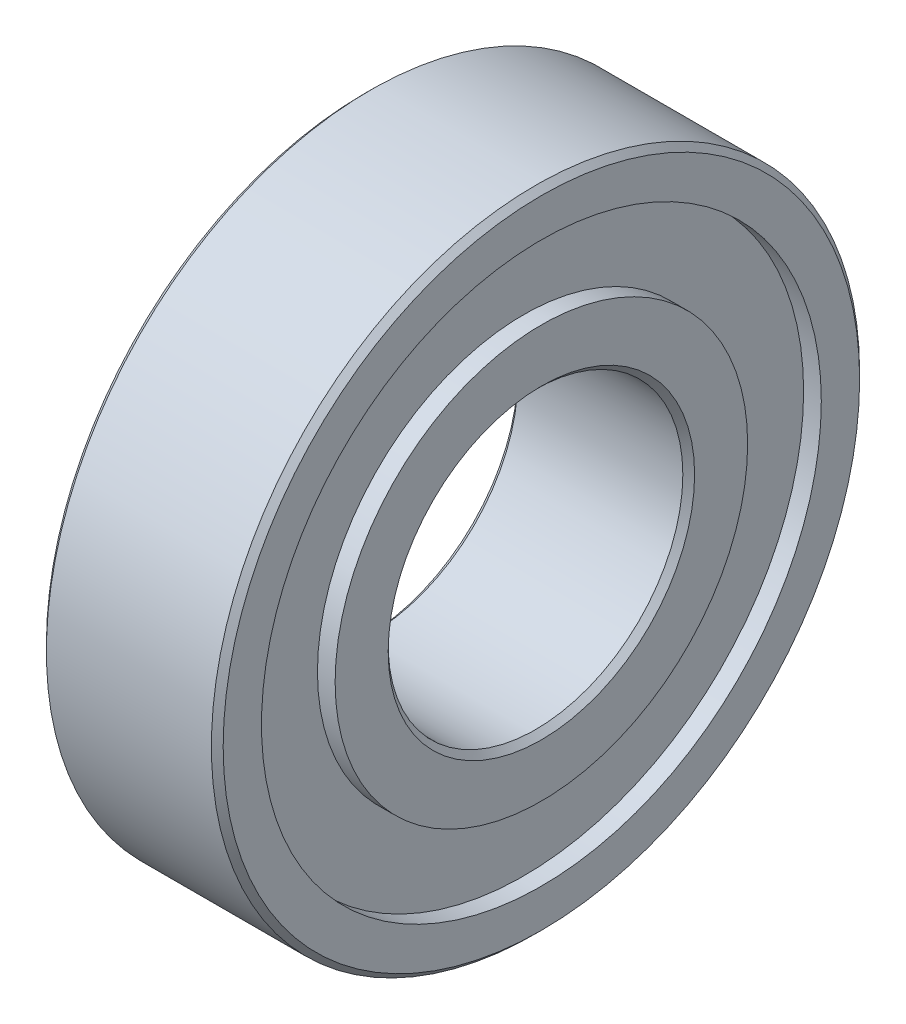
from build123d import *

# Parameters (mm, degrees)
SKETCH_1_R          = 11
SKETCH_1_R_2        = 5
EXTRUDE_1_DEPTH     = 6
SKETCH_2_R          = 9.499624375
SKETCH_2_R_2        = 7
CUT_EXTRUDE_1_DEPTH = 0.6
SKETCH_3_R          = 9.950876812
SKETCH_3_R_2        = 7
CUT_EXTRUDE_2_DEPTH = 0.6
CHAMFER_1_SIZE      = 0.2


with BuildPart() as part:
    # 草图1 → 凸台-拉伸1 (new body)
    with BuildSketch(Plane(origin=(0, 0, 0), x_dir=(0, 0, -1), z_dir=(1, 0, 0))):
        Circle(SKETCH_1_R)
        Circle(SKETCH_1_R_2, mode=Mode.SUBTRACT)
    extrude(amount=EXTRUDE_1_DEPTH)

    # 草图2 → 切除-拉伸1 (cut)
    with BuildSketch(Plane(origin=(6, 0, 0), x_dir=(0, 0, -1), z_dir=(1, 0, 0))):
        with Locations((-0.000375625, 0)):
            Circle(SKETCH_2_R)
        with Locations((-0.000375625, 0)):
            Circle(SKETCH_2_R_2, mode=Mode.SUBTRACT)
    extrude(amount=-CUT_EXTRUDE_1_DEPTH, mode=Mode.SUBTRACT)

    # 草图3 → 切除-拉伸2 (cut)
    with BuildSketch(Plane.ZY):
        with Locations((0.450876812, 0)):
            Circle(SKETCH_3_R)
        with Locations((0.450876812, 0)):
            Circle(SKETCH_3_R_2, mode=Mode.SUBTRACT)
    extrude(amount=-CUT_EXTRUDE_2_DEPTH, mode=Mode.SUBTRACT)

    # 倒角1
    chamfer_1_edges = [part.edges().sort_by_distance(p)[0] for p in [
        (0, 0, 11),
        (6, 0, 11),
        (0, 0, 5),
        (6, 0, 5),
    ]]
    chamfer(chamfer_1_edges, length=CHAMFER_1_SIZE)


solid = part.part
